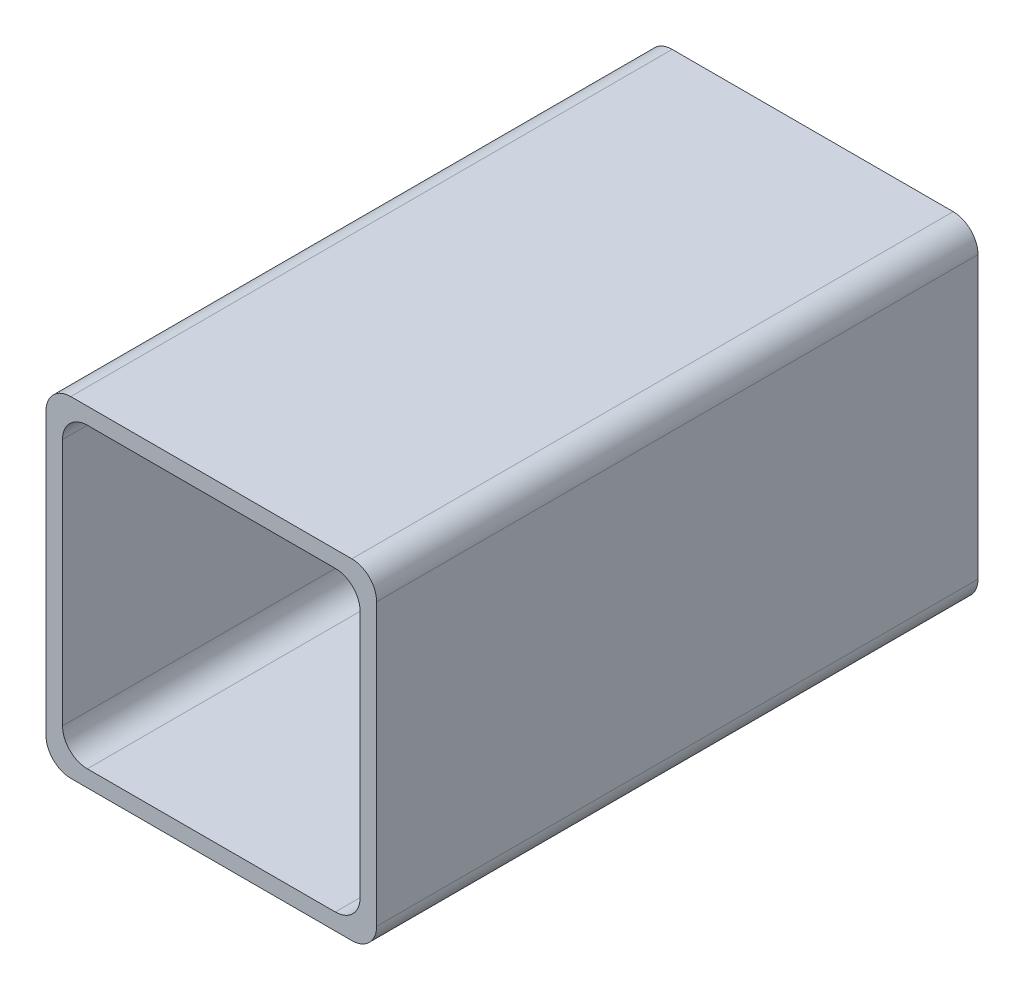
from build123d import *

# Parameters (mm, degrees)
EXTRUDE_1_DEPTH = 72.75


with BuildPart() as part:
    # Эскиз1 → Бобышка-Вытянуть1 (new body)
    with BuildSketch(Plane.XY):
        with BuildLine():
            Line((17, 20), (-17, 20))
            ThreePointArc((-17, 20), (-19.121320344, 19.121320344), (-20, 17))
            Line((-20, 17), (-20, -17))
            ThreePointArc((-20, -17), (-19.121320344, -19.121320344), (-17, -20))
            Line((-17, -20), (17, -20))
            ThreePointArc((17, -20), (19.121320344, -19.121320344), (20, -17))
            Line((20, -17), (20, 17))
            ThreePointArc((20, 17), (19.121320344, 19.121320344), (17, 20))
        make_face()
        with BuildLine():
            Line((-18, -15), (-18, 15))
            ThreePointArc((-18, 15), (-17.121320344, 17.121320344), (-15, 18))
            Line((-15, 18), (15, 18))
            ThreePointArc((15, 18), (17.121320344, 17.121320344), (18, 15))
            Line((18, 15), (18, -15))
            ThreePointArc((18, -15), (17.121320344, -17.121320344), (15, -18))
            Line((15, -18), (-15, -18))
            ThreePointArc((-15, -18), (-17.121320344, -17.121320344), (-18, -15))
        make_face(mode=Mode.SUBTRACT)
    extrude(amount=EXTRUDE_1_DEPTH)


solid = part.part
